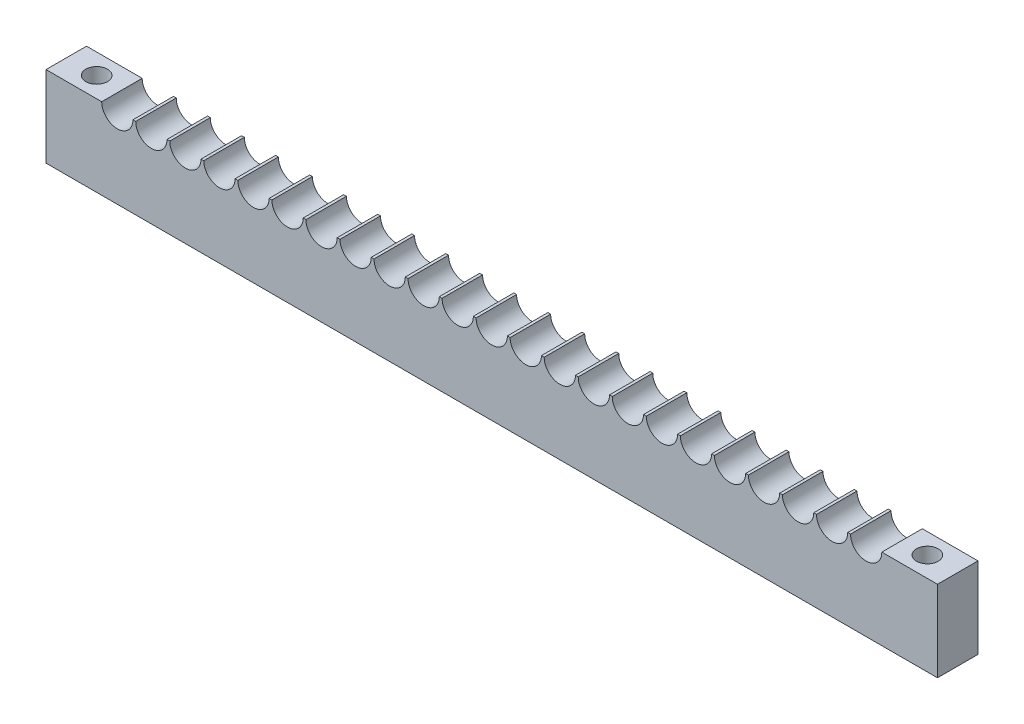
from build123d import *

# Parameters (mm, degrees)
SKETCH1_W            = 139.7
SKETCH1_H            = 12.7
BOSS_EXTRUDE1_DEPTH  = 6.35
SKETCH2_R            = 2.4511
CUT_EXTRUDE1_DEPTH   = 7.35
M3_CLEARANCE_HOLE1_D = 3.4


with BuildPart() as part:
    # Sketch1 → Boss-Extrude1 (new body)
    with BuildSketch(Plane.XY):
        Rectangle(SKETCH1_W, SKETCH1_H)
    extrude(amount=BOSS_EXTRUDE1_DEPTH)

    # Sketch2 → Cut-Extrude1 (cut, through all)
    with BuildSketch(Plane.XY.offset(6.35)):
        with Locations((0, 6.35)):
            Circle(SKETCH2_R)
        with Locations((5.334, 6.35)):
            Circle(SKETCH2_R)
        with Locations((10.668, 6.35)):
            Circle(SKETCH2_R)
        with Locations((16.002, 6.35)):
            Circle(SKETCH2_R)
        with Locations((21.336, 6.35)):
            Circle(SKETCH2_R)
        with Locations((26.67, 6.35)):
            Circle(SKETCH2_R)
        with Locations((32.004, 6.35)):
            Circle(SKETCH2_R)
        with Locations((37.338, 6.35)):
            Circle(SKETCH2_R)
        with Locations((42.672, 6.35)):
            Circle(SKETCH2_R)
        with Locations((48.006, 6.35)):
            Circle(SKETCH2_R)
        with Locations((53.34, 6.35)):
            Circle(SKETCH2_R)
        with Locations((58.674, 6.35)):
            Circle(SKETCH2_R)
        with Locations((-5.334, 6.35)):
            Circle(SKETCH2_R)
        with Locations((-10.668, 6.35)):
            Circle(SKETCH2_R)
        with Locations((-16.002, 6.35)):
            Circle(SKETCH2_R)
        with Locations((-21.336, 6.35)):
            Circle(SKETCH2_R)
        with Locations((-26.67, 6.35)):
            Circle(SKETCH2_R)
        with Locations((-32.004, 6.35)):
            Circle(SKETCH2_R)
        with Locations((-37.338, 6.35)):
            Circle(SKETCH2_R)
        with Locations((-42.672, 6.35)):
            Circle(SKETCH2_R)
        with Locations((-48.006, 6.35)):
            Circle(SKETCH2_R)
        with Locations((-53.34, 6.35)):
            Circle(SKETCH2_R)
        with Locations((-58.674, 6.35)):
            Circle(SKETCH2_R)
    extrude(amount=-CUT_EXTRUDE1_DEPTH, mode=Mode.SUBTRACT)

    # M3 Clearance Hole1 (through all)
    with Locations(Plane(origin=(0, -6.35, 0), x_dir=(-1, 0, 0), z_dir=(0, -1, 0))):
        with Locations((65.0875, -3.175)):
            m3_clearance_hole1 = Hole(M3_CLEARANCE_HOLE1_D / 2)

    # Mirror1: M3 Clearance Hole1 across plane
    add(m3_clearance_hole1.mirror(Plane(origin=(0, 0, 0), x_dir=(0, 0, 1), z_dir=(1, 0, 0))), mode=Mode.SUBTRACT)


solid = part.part
